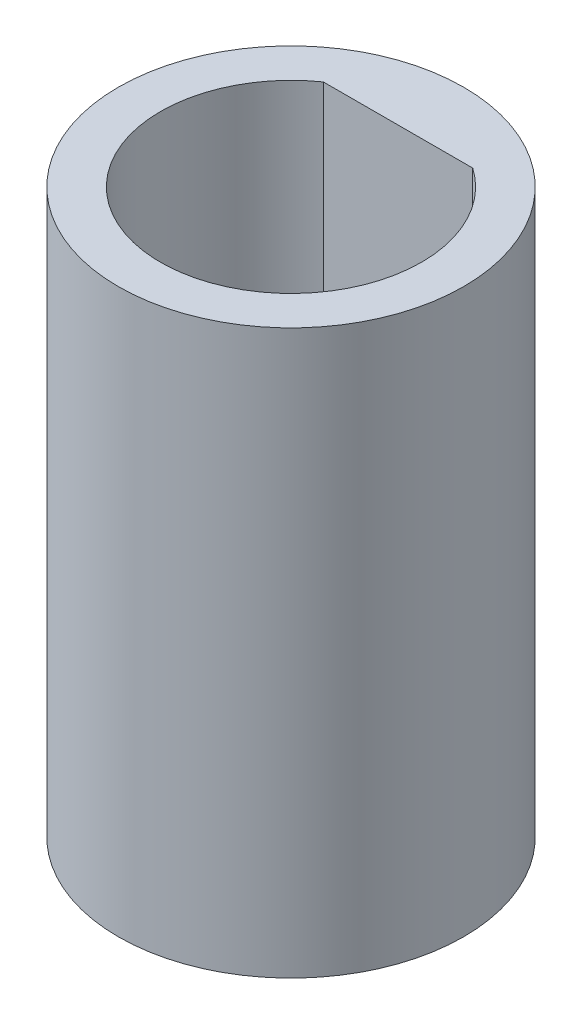
from build123d import *

# Parameters (mm, degrees)
SKETCH1_R           = 5.842
BOSS_EXTRUDE1_DEPTH = 19.05
CUT_EXTRUDE3_DEPTH  = 19.050100076


with BuildPart() as part:
    # Sketch1 → Boss-Extrude1 (new body)
    with BuildSketch(Plane(origin=(0, 0, 0), x_dir=(1, 0, 0), z_dir=(0, 1, 0))):
        Circle(SKETCH1_R)
    extrude(amount=BOSS_EXTRUDE1_DEPTH)

    # Sketch4 → Cut-Extrude3 (cut)
    with BuildSketch(Plane(origin=(0, 19.05, 0), x_dir=(1, 0, 0), z_dir=(0, 1, 0))):
        with BuildLine():
            Line((-2.527748348, 3.621974982), (2.522398786, 3.625702531))
            ThreePointArc((2.522398786, 3.625702531), (0.003260078, -4.416809239), (-2.527748348, 3.621974982))
        make_face()
    extrude(amount=-CUT_EXTRUDE3_DEPTH, mode=Mode.SUBTRACT)


solid = part.part
